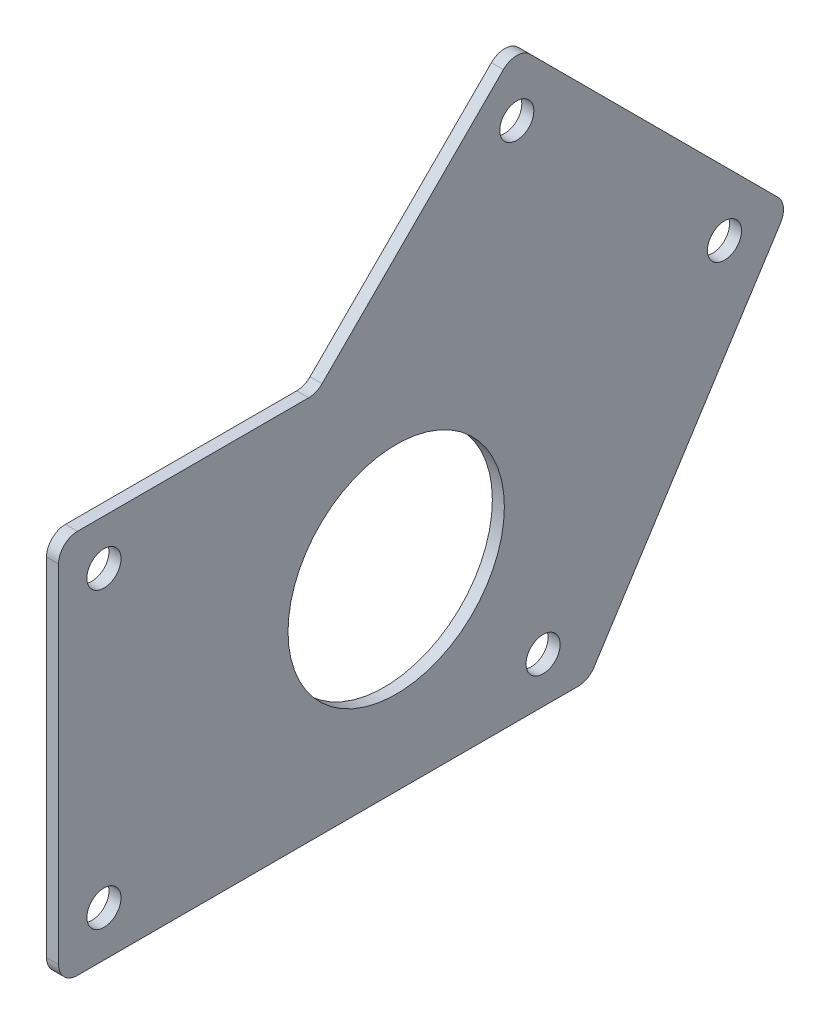
from build123d import *

# Parameters (mm, degrees)
SKETCH1_EXCAVATOR_MASTERSKETCH_3_R   = 2.25
SKETCH1_EXCAVATOR_MASTERSKETCH_3_R_2 = 14.2875
BOSS_EXTRUDE1_DEPTH                  = 1.5875


with BuildPart() as part:
    # Sketch1-Excavator Mastersketch_3 → Boss-Extrude1 (new body)
    with BuildSketch(Plane(origin=(101.6, 0, 0), x_dir=(0, 0, -1), z_dir=(1, 0, 0))):
        with BuildLine():
            Line((87.1, -25.4), (153.231778176, -25.4))
            ThreePointArc((153.231778176, -25.4), (153.945606164, -25.295923539), (154.6, -24.992359682))
            ThreePointArc((154.6, -24.992359682), (155.00822415, -24.65904511), (155.337504304, -24.247559823))
            Line((155.337504304, -24.247559823), (179.961994288, 14.231200859))
            ThreePointArc((179.961994288, 14.231200859), (180.341686112, 15.848385623), (179.624035114, 17.346527635))
            Line((179.624035114, 17.346527635), (146.892536085, 50.078026663))
            ThreePointArc((146.892536085, 50.078026663), (145.124769132, 50.81025971), (143.357002179, 50.078026663))
            Line((143.357002179, 50.078026663), (119.411208563, 26.132233047))
            ThreePointArc((119.411208563, 26.132233047), (118.600150191, 25.590301169), (117.64344161, 25.4))
            Line((117.64344161, 25.4), (87.1, 25.4))
            ThreePointArc((87.1, 25.4), (85.332233047, 24.667766953), (84.6, 22.9))
            Line((84.6, 22.9), (84.6, -22.9))
            ThreePointArc((84.6, -22.9), (85.332233047, -24.667766953), (87.1, -25.4))
        make_face()
        with Locations((90.6, -19.4)):
            Circle(SKETCH1_EXCAVATOR_MASTERSKETCH_3_R, mode=Mode.SUBTRACT)
        with Locations((129.2, 0)):
            Circle(SKETCH1_EXCAVATOR_MASTERSKETCH_3_R_2, mode=Mode.SUBTRACT)
        with Locations((148.6, -19.4)):
            Circle(SKETCH1_EXCAVATOR_MASTERSKETCH_3_R, mode=Mode.SUBTRACT)
        with Locations((90.6, 19.4)):
            Circle(SKETCH1_EXCAVATOR_MASTERSKETCH_3_R, mode=Mode.SUBTRACT)
        with Locations((172.560512242, 15.924769132)):
            Circle(SKETCH1_EXCAVATOR_MASTERSKETCH_3_R, mode=Mode.SUBTRACT)
        with Locations((145.124769132, 43.360512242)):
            Circle(SKETCH1_EXCAVATOR_MASTERSKETCH_3_R, mode=Mode.SUBTRACT)
    extrude(amount=BOSS_EXTRUDE1_DEPTH)


solid = part.part
